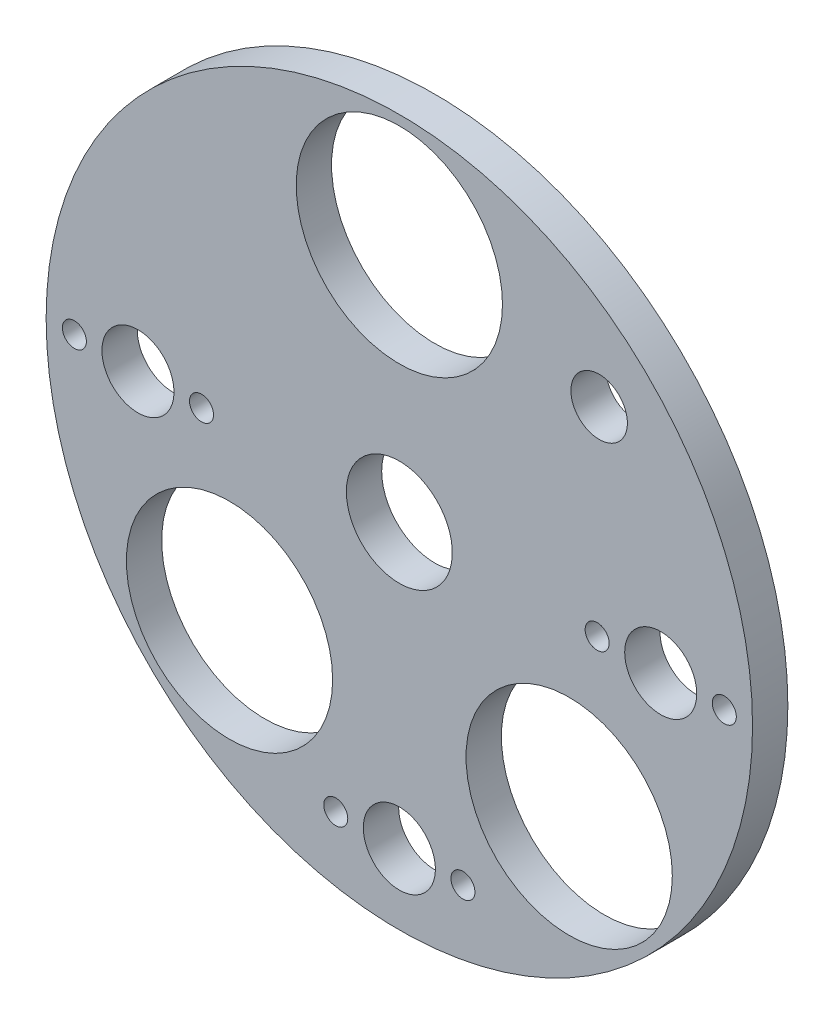
from build123d import *

# Parameters (mm, degrees)
SKETCH1_R                    = 50
BOSS_EXTRUDE1_DEPTH          = 5
F_15_0_15_DIAMETER_HOLE1_D   = 15
F_10_2_10_2_DIAMETER_HOLE1_D = 10.2
M3_CLEARANCE_HOLE1_D         = 3.4
SKETCH9_R                    = 14.6
CUT_EXTRUDE1_DEPTH           = 10
SKETCH10_R                   = 4
CUT_EXTRUDE2_DEPTH           = 10


with BuildPart() as part:
    # Sketch1 → Boss-Extrude1 (new body)
    with BuildSketch(Plane.XY):
        Circle(SKETCH1_R)
    extrude(amount=BOSS_EXTRUDE1_DEPTH)

    # Ø15.0 (15) Diameter Hole1 (through all)
    with Locations(Plane(origin=(0, 0, 0), x_dir=(-1, 0, 0), z_dir=(0, 0, -1))):
        with Locations((0, 0)):
            Hole(F_15_0_15_DIAMETER_HOLE1_D / 2)

    # Ø10.2 (10.2) Diameter Hole1 (through all)
    with Locations(Plane(origin=(0, 0, 0), x_dir=(-1, 0, 0), z_dir=(0, 0, -1))):
        with Locations((37, 0), (-37, 0), (0, -40)):
            Hole(F_10_2_10_2_DIAMETER_HOLE1_D / 2)

    # M3 Clearance Hole1 (through all)
    with Locations(Plane.XY.offset(5)):
        with Locations((46, 0), (28, 0), (9, -40), (-9, -40), (-46, 0), (-28, 0)):
            Hole(M3_CLEARANCE_HOLE1_D / 2)

    # Sketch9 → Cut-Extrude1 (cut)
    with BuildSketch(Plane.XY.offset(5)):
        with Locations((24.04163056, -24.04163056)):
            Circle(SKETCH9_R)
        with Locations((-24.04163056, -24.04163056)):
            Circle(SKETCH9_R)
        with Locations((0, 34)):
            Circle(SKETCH9_R)
    extrude(amount=-CUT_EXTRUDE1_DEPTH, mode=Mode.SUBTRACT)

    # Sketch10 → Cut-Extrude2 (cut)
    with BuildSketch(Plane.XY.offset(5)):
        with Locations((28.284271247, 28.284271247)):
            Circle(SKETCH10_R)
    extrude(amount=-CUT_EXTRUDE2_DEPTH, mode=Mode.SUBTRACT)


solid = part.part
